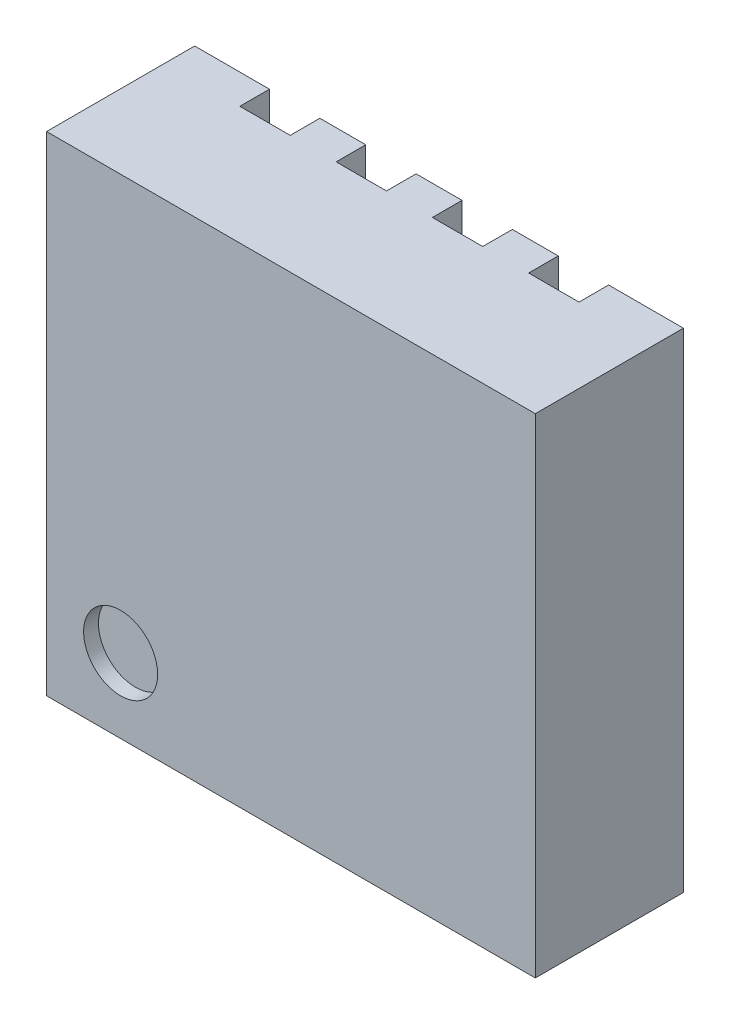
from build123d import *

# Parameters (mm, degrees)
SKETCH_1_W          = 3.3
SKETCH_1_H          = 3.3
EXTRUDE_1_DEPTH     = 1
SKETCH_2_R          = 0.25
CUT_EXTRUDE_1_DEPTH = 0.1
SKETCH_3_W          = 0.34
SKETCH_3_H          = 0.5
CUT_EXTRUDE_2_DEPTH = 0.2


with BuildPart() as part:
    # Эскиз1 → Бобышка-Вытянуть1 (new body)
    with BuildSketch(Plane.XY):
        Rectangle(SKETCH_1_W, SKETCH_1_H)
    extrude(amount=EXTRUDE_1_DEPTH)

    # Эскиз2 → Вырез-Вытянуть1 (cut)
    with BuildSketch(Plane.XY.offset(1)):
        with Locations((-1.15, -1.15)):
            Circle(SKETCH_2_R)
    extrude(amount=-CUT_EXTRUDE_1_DEPTH, mode=Mode.SUBTRACT)

    # Эскиз3 → Вырез-Вытянуть2 (cut)
    with BuildSketch(Plane(origin=(0, 0, 0), x_dir=(-1, 0, 0), z_dir=(0, 0, -1))):
        Polygon((-1.145, 1.65), (-1.145, -0.46), (1.145, -0.46), (1.145, 1.65), (0.805, 1.65), (0.805, 1.25), (0.495, 1.25), (0.495, 1.65), (0.155, 1.65), (0.155, 1.25), (-0.155, 1.25), (-0.155, 1.65), (-0.495, 1.65), (-0.495, 1.25), (-0.805, 1.25), (-0.805, 1.65), align=None)
        Polygon((1.145, -1.65), (1.145, -1.05), (-0.495, -1.05), (-0.495, -1.65), (-0.155, -1.65), (-0.155, -1.45), (0.155, -1.45), (0.155, -1.65), (0.495, -1.65), (0.495, -1.45), (0.805, -1.45), (0.805, -1.65), align=None)
        with Locations((-0.975, -1.4)):
            Rectangle(SKETCH_3_W, SKETCH_3_H)
    extrude(amount=-CUT_EXTRUDE_2_DEPTH, mode=Mode.SUBTRACT)


solid = part.part
